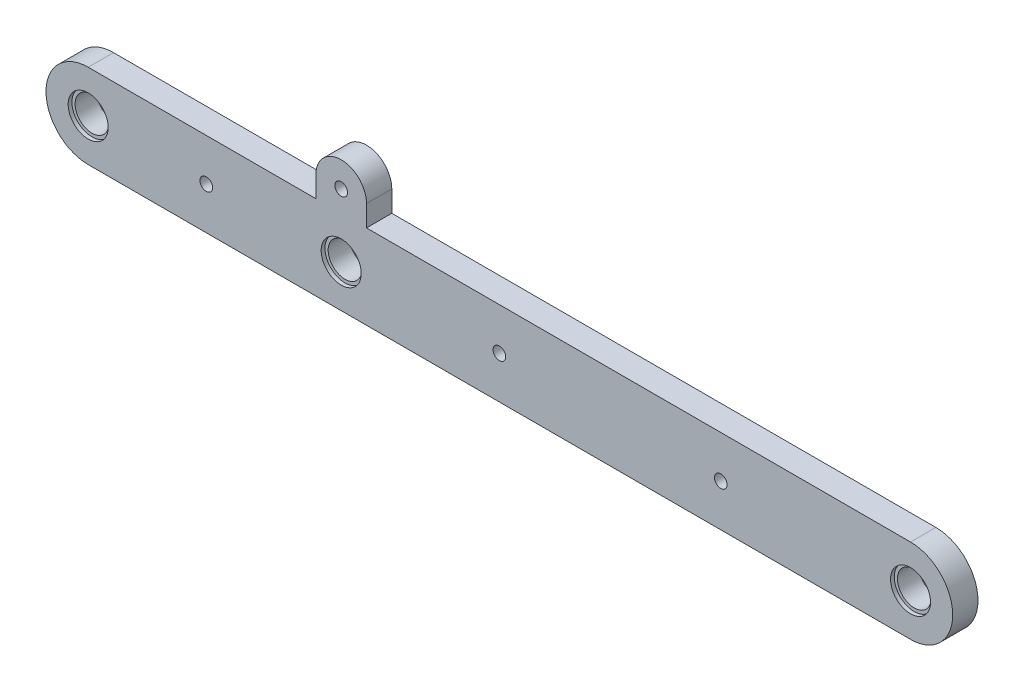
from build123d import *

# Parameters (mm, degrees)
EXTRUDE_1_DEPTH              = 6
HOLE_WIZARD_M5_1_D           = 8
HOLE_WIZARD_M5_1_CBORE_D     = 9.5
HOLE_WIZARD_M5_1_CBORE_DEPTH = 0.9
SKETCH_7_R                   = 1.5
CUT_EXTRUDE_1_DEPTH          = 1
CUT_EXTRUDE_1_DEPTH_BACK     = 7


with BuildPart() as part:
    # 草图1 → 凸台-拉伸1 (new body)
    with BuildSketch(Plane.XY):
        with BuildLine():
            Line((-60, -10), (135, -10))
            ThreePointArc((135, -10), (145, 0), (135, 10))
            Line((135, 10), (6, 10))
            Line((6, 10), (6, 15))
            ThreePointArc((6, 15), (0, 21), (-6, 15))
            Line((-6, 15), (-6, 10))
            Line((-6, 10), (-60, 10))
            ThreePointArc((-60, 10), (-70, 0), (-60, -10))
        make_face()
    extrude(amount=EXTRUDE_1_DEPTH)

    # M5 六角头螺栓的柱形沉头孔1 (through all)
    with Locations(Plane(origin=(0, 0, 6), x_dir=(-1, 0, 0), z_dir=(0, 0, 1))):
        with Locations((-135, 0), (60, 0), (0, 0)):
            CounterBoreHole(HOLE_WIZARD_M5_1_D / 2, HOLE_WIZARD_M5_1_CBORE_D / 2, HOLE_WIZARD_M5_1_CBORE_DEPTH)

    # 草图7 → 切除-拉伸1 (cut, two sides)
    with BuildSketch(Plane(origin=(0, 0, 0), x_dir=(-1, 0, 0), z_dir=(0, 0, -1))) as cut_extrude_1_sk:
        with Locations((-37.5, 0)):
            Circle(SKETCH_7_R)
        with Locations((-90, 0)):
            Circle(SKETCH_7_R)
        with Locations((32, 0)):
            Circle(SKETCH_7_R)
        with Locations((0, 15)):
            Circle(SKETCH_7_R)
    extrude(amount=CUT_EXTRUDE_1_DEPTH, mode=Mode.SUBTRACT)
    extrude(cut_extrude_1_sk.sketch, amount=-CUT_EXTRUDE_1_DEPTH_BACK, mode=Mode.SUBTRACT)


solid = part.part
